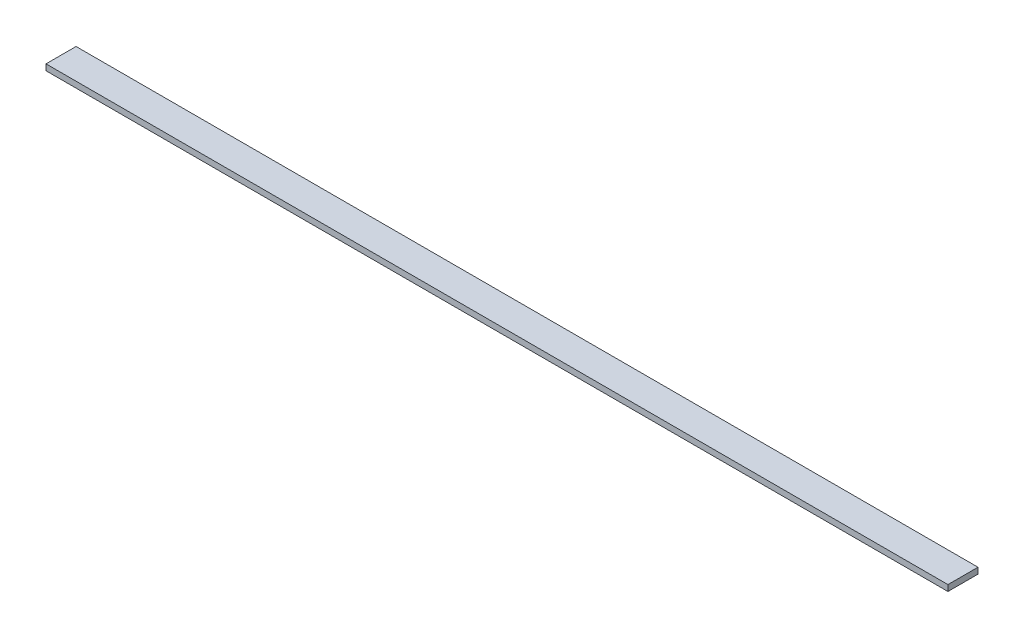
from build123d import *

# Parameters (mm, degrees)
SKETCH_1_W      = 1200
SKETCH_1_H      = 40
EXTRUDE_1_DEPTH = 8


with BuildPart() as part:
    # Эскиз1 → Бобышка-Вытянуть1 (new body)
    with BuildSketch(Plane(origin=(0, 0, 0), x_dir=(1, 0, 0), z_dir=(0, 1, 0))):
        Rectangle(SKETCH_1_W, SKETCH_1_H)
    extrude(amount=EXTRUDE_1_DEPTH)


solid = part.part
